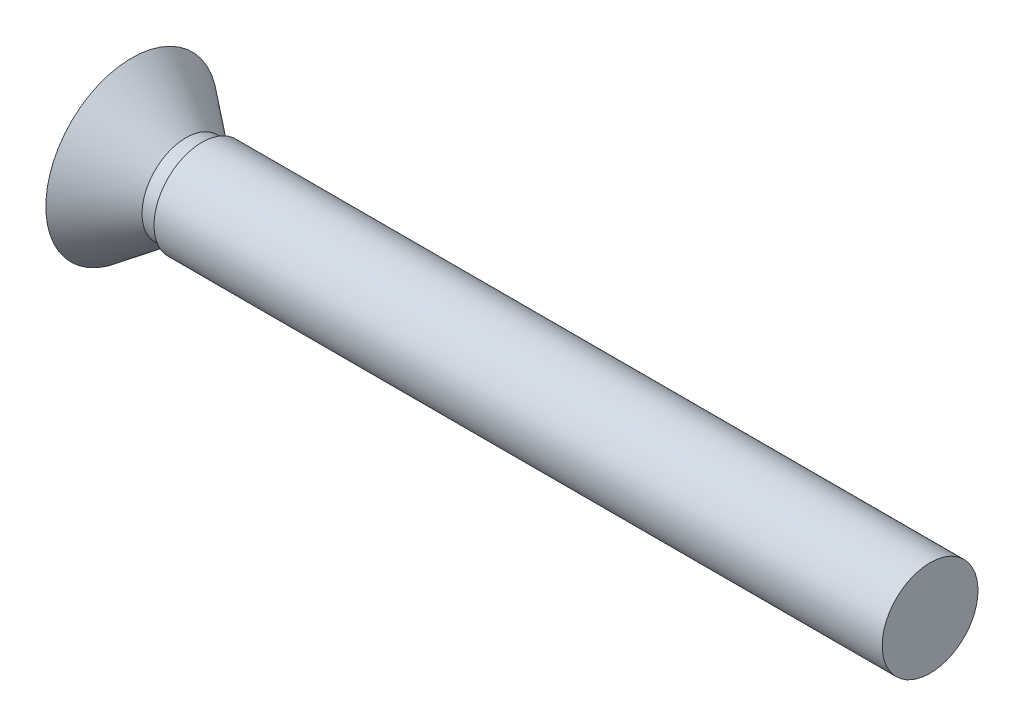
from build123d import *


with BuildPart() as part:
    # Sketch2 → Revolve1 (revolve)
    with BuildSketch(Plane(origin=(0, 0, 0), x_dir=(1, 0, 0), z_dir=(0, 1, 0))):
        Polygon((0, 0), (-46.6, 0), (-50, 0), (-50, 5.375), (-46.6, 2.75), (-45.6, 2.75), (-45.6, 3), (0, 3), align=None)
    revolve(axis=Axis((0, 0, 0), (-1, 0, 0)))


solid = part.part
